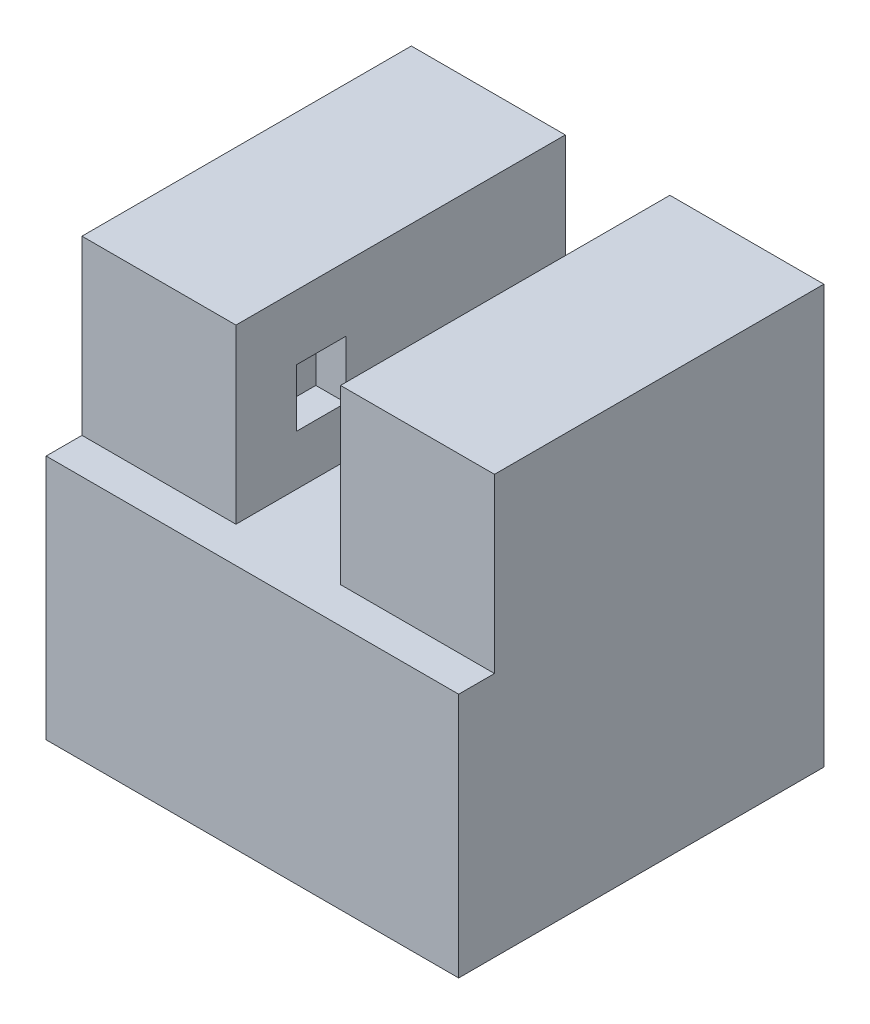
from build123d import *

# Parameters (mm, degrees)
SKETCH2_W           = 18.7
SKETCH2_H           = 20
BOSS_EXTRUDE1_DEPTH = 25.4
SKETCH3_W           = 6.35
SKETCH3_H           = 7.3
SKETCH3_H_2         = 3.175
CUT_EXTRUDE1_DEPTH  = 21
SKETCH5_W           = 3.175
SKETCH5_H           = 25.4
BOSS_EXTRUDE2_DEPTH = 20
SKETCH6_W           = 10
SKETCH6_H           = 10.125
CUT_EXTRUDE2_DEPTH  = 16.825
SKETCH7_W           = 3
SKETCH7_H           = 3.5
CUT_EXTRUDE3_DEPTH  = 10
SKETCH8_W           = 22
SKETCH8_H           = 10.125
CUT_EXTRUDE4_DEPTH  = 19
SKETCH9_W           = 2.175
SKETCH9_H           = 14.925
BOSS_EXTRUDE3_DEPTH = 25.05


with BuildPart() as part:
    # Sketch2 → Boss-Extrude1 (new body)
    with BuildSketch(Plane(origin=(0, 0, 0), x_dir=(1, 0, 0), z_dir=(0, 1, 0))):
        Rectangle(SKETCH2_W, SKETCH2_H)
    extrude(amount=BOSS_EXTRUDE1_DEPTH)

    # Sketch3 → Cut-Extrude1 (cut, through all)
    with BuildSketch(Plane(origin=(0, 0, -10), x_dir=(-1, 0, 0), z_dir=(0, 0, -1))):
        with Locations((0, 21.75)):
            Rectangle(SKETCH3_W, SKETCH3_H)
        with Locations((0, 16.5125)):
            Rectangle(SKETCH3_W, SKETCH3_H_2)
    extrude(amount=-CUT_EXTRUDE1_DEPTH, mode=Mode.SUBTRACT)

    # Sketch5 → Boss-Extrude2 (add)
    with BuildSketch(Plane(origin=(0, 0, -10), x_dir=(-1, 0, 0), z_dir=(0, 0, -1))):
        with Locations((-10.9375, 12.7)):
            Rectangle(SKETCH5_W, SKETCH5_H)
        with Locations((10.9375, 12.7)):
            Rectangle(SKETCH5_W, SKETCH5_H)
    extrude(amount=-BOSS_EXTRUDE2_DEPTH)

    # Sketch6 → Cut-Extrude2 (cut)
    with BuildSketch(Plane(origin=(0, 0, -10), x_dir=(-1, 0, 0), z_dir=(0, 0, -1))):
        Polygon((5, 22.225), (5, 10.125), (5, 0), (9.35, 0), (9.35, 22.225), align=None)
        with Locations((0, 5.0625)):
            Rectangle(SKETCH6_W, SKETCH6_H)
        Polygon((-5, 22.225), (-9.35, 22.225), (-9.35, 0), (-5, 0), (-5, 10.125), align=None)
    extrude(amount=-CUT_EXTRUDE2_DEPTH, mode=Mode.SUBTRACT)

    # Sketch7 → Cut-Extrude3 (cut)
    with BuildSketch(Plane(origin=(5, 0, 0), x_dir=(0, 0, -1), z_dir=(1, 0, 0))):
        with Locations((-4.825, 19.725)):
            Rectangle(SKETCH7_W, SKETCH7_H)
    extrude(amount=-CUT_EXTRUDE3_DEPTH, mode=Mode.SUBTRACT)

    # Sketch8 → Cut-Extrude4 (cut)
    with BuildSketch(Plane(origin=(0, 0, -10), x_dir=(-1, 0, 0), z_dir=(0, 0, -1))):
        with Locations((0, 5.0625)):
            Rectangle(SKETCH8_W, SKETCH8_H)
    extrude(amount=-CUT_EXTRUDE4_DEPTH, mode=Mode.SUBTRACT)

    # Sketch9 → Boss-Extrude3 (add)
    with BuildSketch(Plane(origin=(12.525, 0, 0), x_dir=(0, 0, -1), z_dir=(1, 0, 0))):
        with Locations((-11.0875, 7.4625)):
            Rectangle(SKETCH9_W, SKETCH9_H)
    extrude(amount=-BOSS_EXTRUDE3_DEPTH)


solid = part.part
